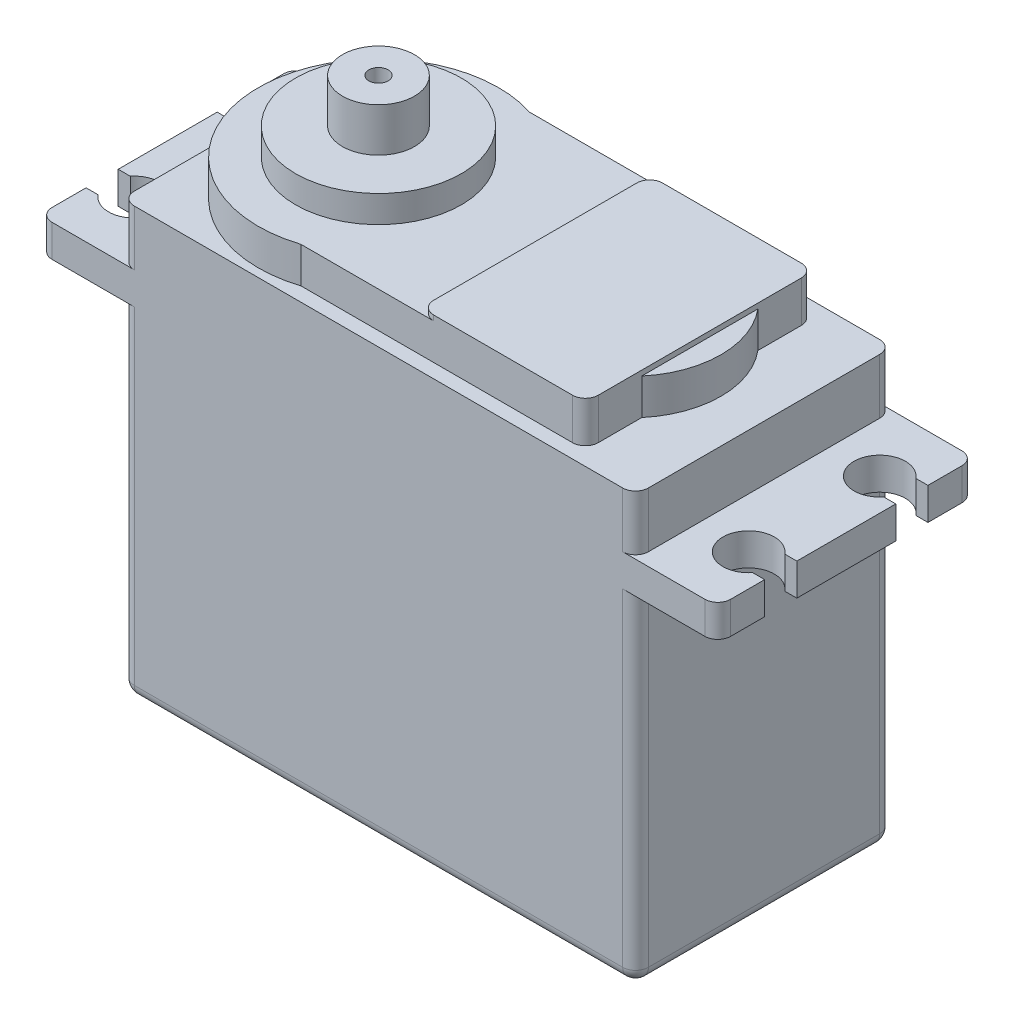
from build123d import *

# Parameters (mm, degrees)
EXTRUDE_1_DEPTH             = 33.3
EXTRUDE_START               = -26.5
EXTRUDE_2_DEPTH             = 2.5
EXTRUDE_START_2             = -33.3
EXTRUDE_3_DEPTH             = 36.1
EXTRUDE_4_DEPTH             = 0.4
SKETCH_6_R                  = 6.45
EXTRUDE_5_DEPTH             = 2.1
SKETCH_7_R                  = 2.8
SKETCH_7_R_2                = 0.75
EXTRUDE_6_DEPTH             = 3.4
FILLET_1_R                  = 1
CUT_EXTRUDE_1_REACH         = 60.258
SKETCH_8_R                  = 2
EXTRUDE_7_DEPTH             = 4.4
EXTRUDE_7_DIRECTION_2_REACH = 67.449


with BuildPart() as part:
    # Эскиз1 → Вытянуть1 (new body)
    with BuildSketch(Plane(origin=(0, 0, 0), x_dir=(1, 0, 0), z_dir=(0, 1, 0))):
        with BuildLine():
            Line((1, 0), (39, 0))
            ThreePointArc((39, 0), (39.707106781, 0.292893219), (40, 1))
            Line((40, 1), (40, 19))
            ThreePointArc((40, 19), (39.707106781, 19.707106781), (39, 20))
            Line((39, 20), (1, 20))
            ThreePointArc((1, 20), (0.292893219, 19.707106781), (0, 19))
            Line((0, 19), (0, 1))
            ThreePointArc((0, 1), (0.292893219, 0.292893219), (1, 0))
        make_face()
    extrude(amount=EXTRUDE_1_DEPTH)

    # Эскиз2 → Вытянуть2 (add)
    with BuildSketch(Plane.XZ.offset(EXTRUDE_START)):
        with BuildLine():
            Line((-5.4, 0), (45.4, 0))
            ThreePointArc((45.4, 0), (46.107106781, -0.292893219), (46.4, -1))
            Line((46.4, -1), (46.4, -19))
            ThreePointArc((46.4, -19), (46.107106781, -19.707106781), (45.4, -20))
            Line((45.4, -20), (-5.4, -20))
            ThreePointArc((-5.4, -20), (-6.107106781, -19.707106781), (-6.4, -19))
            Line((-6.4, -19), (-6.4, -1))
            ThreePointArc((-6.4, -1), (-6.107106781, -0.292893219), (-5.4, 0))
        make_face()
    extrude(amount=-EXTRUDE_2_DEPTH)

    # Эскиз3 → Вытянуть3 (add)
    with BuildSketch(Plane(origin=(0, 33.3, 0), x_dir=(1, 0, 0), z_dir=(0, 1, 0)).offset(EXTRUDE_START_2)):
        with BuildLine():
            Line((12.865745976, 18.9), (34, 18.9))
            ThreePointArc((34, 18.9), (34.707106781, 18.607106781), (35, 17.9))
            Line((35, 17.9), (35, 14.514144437))
            ThreePointArc((35, 14.514144437), (36.65, 10), (35, 5.485855563))
            Line((35, 5.485855563), (35, 2.1))
            ThreePointArc((35, 2.1), (34.707106781, 1.392893219), (34, 1.1))
            Line((34, 1.1), (12.865745976, 1.1))
            ThreePointArc((12.865745976, 1.1), (0.65, 10), (12.865745976, 18.9))
        make_face()
    extrude(amount=EXTRUDE_3_DEPTH)

    # Эскиз5 → Вытянуть4 (add)
    with BuildSketch(Plane(origin=(0, 36.1, 0), x_dir=(1, 0, 0), z_dir=(0, 1, 0))):
        with BuildLine():
            Line((23.2, 18.9), (34, 18.9))
            ThreePointArc((34, 18.9), (34.707106781, 18.607106781), (35, 17.9))
            Line((35, 17.9), (35, 2.1))
            ThreePointArc((35, 2.1), (34.707106781, 1.392893219), (34, 1.1))
            Line((34, 1.1), (23.2, 1.1))
            ThreePointArc((23.2, 1.1), (22.492893219, 1.392893219), (22.2, 2.1))
            Line((22.2, 2.1), (22.2, 17.9))
            ThreePointArc((22.2, 17.9), (22.492893219, 18.607106781), (23.2, 18.9))
        make_face()
    extrude(amount=EXTRUDE_4_DEPTH)

    # Эскиз6 → Вытянуть5 (add)
    with BuildSketch(Plane(origin=(0, 36.1, 0), x_dir=(1, 0, 0), z_dir=(0, 1, 0))):
        with Locations(Location((10, 10, 0), (0, 0, 270))):
            Circle(SKETCH_6_R)
    extrude(amount=EXTRUDE_5_DEPTH)

    # Эскиз7 → Вытянуть6 (add)
    with BuildSketch(Plane(origin=(0, 38.2, 0), x_dir=(1, 0, 0), z_dir=(0, 1, 0))):
        with Locations(Location((10, 10, 0), (0, 0, 270))):
            Circle(SKETCH_7_R)
        with Locations(Location((10, 10, 0), (0, 0, 270))):
            Circle(SKETCH_7_R_2, mode=Mode.SUBTRACT)
    extrude(amount=EXTRUDE_6_DEPTH)

    # Скругление1
    fillet_1_edges = [part.edges().sort_by_distance(p)[0] for p in [
        (20, 0, -20),
        (39.707106781, 0, -19.707106781),
        (40, 0, -10),
        (39.707106781, 0, -0.292893219),
        (20, 0, 0),
        (0.292893219, 0, -0.292893219),
        (0, 0, -10),
        (0.292893219, 0, -19.707106781),
    ]]
    fillet(fillet_1_edges, radius=FILLET_1_R)

    # Эскиз8 → Вырез-Вытянуть1 (cut, up to next)
    with BuildSketch(Plane(origin=(0, 29, 0), x_dir=(1, 0, 0), z_dir=(0, 1, 0)), mode=Mode.PRIVATE) as cut_extrude_1_sk1:
        with Locations((-3.9, 4.9)):
            Circle(SKETCH_8_R)
    cut_extrude_1_tool1 = extrude(cut_extrude_1_sk1.sketch, amount=-CUT_EXTRUDE_1_REACH, mode=Mode.PRIVATE) & part.part
    # Эскиз8 → Вырез-Вытянуть1 (cut, up to next)
    with BuildSketch(Plane(origin=(0, 29, 0), x_dir=(1, 0, 0), z_dir=(0, 1, 0)), mode=Mode.PRIVATE) as cut_extrude_1_sk2:
        with Locations((-3.9, 15.1)):
            Circle(SKETCH_8_R)
    cut_extrude_1_tool2 = extrude(cut_extrude_1_sk2.sketch, amount=-CUT_EXTRUDE_1_REACH, mode=Mode.PRIVATE) & part.part
    # Эскиз8 → Вырез-Вытянуть1 (cut, up to next)
    with BuildSketch(Plane(origin=(0, 29, 0), x_dir=(1, 0, 0), z_dir=(0, 1, 0)), mode=Mode.PRIVATE) as cut_extrude_1_sk3:
        with Locations((43.9, 15.1)):
            Circle(SKETCH_8_R)
    cut_extrude_1_tool3 = extrude(cut_extrude_1_sk3.sketch, amount=-CUT_EXTRUDE_1_REACH, mode=Mode.PRIVATE) & part.part
    # Эскиз8 → Вырез-Вытянуть1 (cut, up to next)
    with BuildSketch(Plane(origin=(0, 29, 0), x_dir=(1, 0, 0), z_dir=(0, 1, 0)), mode=Mode.PRIVATE) as cut_extrude_1_sk4:
        with Locations((43.9, 4.9)):
            Circle(SKETCH_8_R)
    cut_extrude_1_tool4 = extrude(cut_extrude_1_sk4.sketch, amount=-CUT_EXTRUDE_1_REACH, mode=Mode.PRIVATE) & part.part
    # Эскиз8 → Вырез-Вытянуть1 (cut, up to next)
    with BuildSketch(Plane(origin=(0, 29, 0), x_dir=(1, 0, 0), z_dir=(0, 1, 0)), mode=Mode.PRIVATE) as cut_extrude_1_sk5:
        with BuildLine():
            ThreePointArc((-5.4612495, 13.85), (-5.9, 15.1), (-5.4612495, 16.35))
            Line((-5.4612495, 16.35), (-6.4, 16.35))
            Line((-6.4, 16.35), (-6.4, 13.85))
            Line((-6.4, 13.85), (-5.4612495, 13.85))
        make_face()
    cut_extrude_1_tool5 = extrude(cut_extrude_1_sk5.sketch, amount=-CUT_EXTRUDE_1_REACH, mode=Mode.PRIVATE) & part.part
    # Эскиз8 → Вырез-Вытянуть1 (cut, up to next)
    with BuildSketch(Plane(origin=(0, 29, 0), x_dir=(1, 0, 0), z_dir=(0, 1, 0)), mode=Mode.PRIVATE) as cut_extrude_1_sk6:
        with BuildLine():
            ThreePointArc((-1.9, 15.1), (-3.237617557, 16.987127314), (-5.4612495, 16.35))
            Line((-5.4612495, 16.35), (-5.4612495, 13.85))
            ThreePointArc((-5.4612495, 13.85), (-3.237617557, 13.212872686), (-1.9, 15.1))
        make_face()
    cut_extrude_1_tool6 = extrude(cut_extrude_1_sk6.sketch, amount=-CUT_EXTRUDE_1_REACH, mode=Mode.PRIVATE) & part.part
    # Эскиз8 → Вырез-Вытянуть1 (cut, up to next)
    with BuildSketch(Plane(origin=(0, 29, 0), x_dir=(1, 0, 0), z_dir=(0, 1, 0)), mode=Mode.PRIVATE) as cut_extrude_1_sk7:
        with BuildLine():
            Line((-5.4612495, 13.85), (-5.4612495, 16.35))
            ThreePointArc((-5.4612495, 16.35), (-5.9, 15.1), (-5.4612495, 13.85))
        make_face()
    cut_extrude_1_tool7 = extrude(cut_extrude_1_sk7.sketch, amount=-CUT_EXTRUDE_1_REACH, mode=Mode.PRIVATE) & part.part
    # Эскиз8 → Вырез-Вытянуть1 (cut, up to next)
    with BuildSketch(Plane(origin=(0, 29, 0), x_dir=(1, 0, 0), z_dir=(0, 1, 0)), mode=Mode.PRIVATE) as cut_extrude_1_sk8:
        with BuildLine():
            ThreePointArc((-1.9, 4.9), (-3.237617557, 6.787127314), (-5.4612495, 6.15))
            Line((-5.4612495, 6.15), (-5.4612495, 3.65))
            ThreePointArc((-5.4612495, 3.65), (-3.237617557, 3.012872686), (-1.9, 4.9))
        make_face()
    cut_extrude_1_tool8 = extrude(cut_extrude_1_sk8.sketch, amount=-CUT_EXTRUDE_1_REACH, mode=Mode.PRIVATE) & part.part
    # Эскиз8 → Вырез-Вытянуть1 (cut, up to next)
    with BuildSketch(Plane(origin=(0, 29, 0), x_dir=(1, 0, 0), z_dir=(0, 1, 0)), mode=Mode.PRIVATE) as cut_extrude_1_sk9:
        with BuildLine():
            Line((-5.4612495, 3.65), (-5.4612495, 6.15))
            ThreePointArc((-5.4612495, 6.15), (-5.9, 4.9), (-5.4612495, 3.65))
        make_face()
    cut_extrude_1_tool9 = extrude(cut_extrude_1_sk9.sketch, amount=-CUT_EXTRUDE_1_REACH, mode=Mode.PRIVATE) & part.part
    # Эскиз8 → Вырез-Вытянуть1 (cut, up to next)
    with BuildSketch(Plane(origin=(0, 29, 0), x_dir=(1, 0, 0), z_dir=(0, 1, 0)), mode=Mode.PRIVATE) as cut_extrude_1_sk10:
        with BuildLine():
            Line((-5.4612495, 6.15), (-6.4, 6.15))
            Line((-6.4, 6.15), (-6.4, 3.65))
            Line((-6.4, 3.65), (-5.4612495, 3.65))
            ThreePointArc((-5.4612495, 3.65), (-5.9, 4.9), (-5.4612495, 6.15))
        make_face()
    cut_extrude_1_tool10 = extrude(cut_extrude_1_sk10.sketch, amount=-CUT_EXTRUDE_1_REACH, mode=Mode.PRIVATE) & part.part
    # Эскиз8 → Вырез-Вытянуть1 (cut, up to next)
    with BuildSketch(Plane(origin=(0, 29, 0), x_dir=(1, 0, 0), z_dir=(0, 1, 0)), mode=Mode.PRIVATE) as cut_extrude_1_sk11:
        with BuildLine():
            ThreePointArc((45.9, 15.1), (45.787127314, 15.762382443), (45.4612495, 16.35))
            Line((45.4612495, 16.35), (45.4612495, 13.85))
            ThreePointArc((45.4612495, 13.85), (45.787127314, 14.437617557), (45.9, 15.1))
        make_face()
    cut_extrude_1_tool11 = extrude(cut_extrude_1_sk11.sketch, amount=-CUT_EXTRUDE_1_REACH, mode=Mode.PRIVATE) & part.part
    # Эскиз8 → Вырез-Вытянуть1 (cut, up to next)
    with BuildSketch(Plane(origin=(0, 29, 0), x_dir=(1, 0, 0), z_dir=(0, 1, 0)), mode=Mode.PRIVATE) as cut_extrude_1_sk12:
        with BuildLine():
            Line((45.4612495, 13.85), (45.4612495, 16.35))
            ThreePointArc((45.4612495, 16.35), (41.9, 15.1), (45.4612495, 13.85))
        make_face()
    cut_extrude_1_tool12 = extrude(cut_extrude_1_sk12.sketch, amount=-CUT_EXTRUDE_1_REACH, mode=Mode.PRIVATE) & part.part
    # Эскиз8 → Вырез-Вытянуть1 (cut, up to next)
    with BuildSketch(Plane(origin=(0, 29, 0), x_dir=(1, 0, 0), z_dir=(0, 1, 0)), mode=Mode.PRIVATE) as cut_extrude_1_sk13:
        with BuildLine():
            Line((46.4, 16.35), (45.4612495, 16.35))
            ThreePointArc((45.4612495, 16.35), (45.787127314, 15.762382443), (45.9, 15.1))
            ThreePointArc((45.9, 15.1), (45.787127314, 14.437617557), (45.4612495, 13.85))
            Line((45.4612495, 13.85), (46.4, 13.85))
            Line((46.4, 13.85), (46.4, 16.35))
        make_face()
    cut_extrude_1_tool13 = extrude(cut_extrude_1_sk13.sketch, amount=-CUT_EXTRUDE_1_REACH, mode=Mode.PRIVATE) & part.part
    # Эскиз8 → Вырез-Вытянуть1 (cut, up to next)
    with BuildSketch(Plane(origin=(0, 29, 0), x_dir=(1, 0, 0), z_dir=(0, 1, 0)), mode=Mode.PRIVATE) as cut_extrude_1_sk14:
        with BuildLine():
            ThreePointArc((45.9, 4.9), (45.787127314, 5.562382443), (45.4612495, 6.15))
            Line((45.4612495, 6.15), (45.4612495, 3.65))
            ThreePointArc((45.4612495, 3.65), (45.787127314, 4.237617557), (45.9, 4.9))
        make_face()
    cut_extrude_1_tool14 = extrude(cut_extrude_1_sk14.sketch, amount=-CUT_EXTRUDE_1_REACH, mode=Mode.PRIVATE) & part.part
    # Эскиз8 → Вырез-Вытянуть1 (cut, up to next)
    with BuildSketch(Plane(origin=(0, 29, 0), x_dir=(1, 0, 0), z_dir=(0, 1, 0)), mode=Mode.PRIVATE) as cut_extrude_1_sk15:
        with BuildLine():
            Line((45.4612495, 3.65), (45.4612495, 6.15))
            ThreePointArc((45.4612495, 6.15), (41.9, 4.9), (45.4612495, 3.65))
        make_face()
    cut_extrude_1_tool15 = extrude(cut_extrude_1_sk15.sketch, amount=-CUT_EXTRUDE_1_REACH, mode=Mode.PRIVATE) & part.part
    # Эскиз8 → Вырез-Вытянуть1 (cut, up to next)
    with BuildSketch(Plane(origin=(0, 29, 0), x_dir=(1, 0, 0), z_dir=(0, 1, 0)), mode=Mode.PRIVATE) as cut_extrude_1_sk16:
        with BuildLine():
            Line((46.4, 6.15), (45.4612495, 6.15))
            ThreePointArc((45.4612495, 6.15), (45.787127314, 5.562382443), (45.9, 4.9))
            ThreePointArc((45.9, 4.9), (45.787127314, 4.237617557), (45.4612495, 3.65))
            Line((45.4612495, 3.65), (46.4, 3.65))
            Line((46.4, 3.65), (46.4, 6.15))
        make_face()
    cut_extrude_1_tool16 = extrude(cut_extrude_1_sk16.sketch, amount=-CUT_EXTRUDE_1_REACH, mode=Mode.PRIVATE) & part.part
    add(cut_extrude_1_tool1.solids().sort_by_distance((-3.9, 29, -4.9))[0], mode=Mode.SUBTRACT)
    add(cut_extrude_1_tool2.solids().sort_by_distance((-3.9, 29, -15.1))[0], mode=Mode.SUBTRACT)
    add(cut_extrude_1_tool3.solids().sort_by_distance((43.9, 29, -15.1))[0], mode=Mode.SUBTRACT)
    add(cut_extrude_1_tool4.solids().sort_by_distance((43.9, 29, -4.9))[0], mode=Mode.SUBTRACT)
    add(cut_extrude_1_tool5.solids().sort_by_distance((-6.067542, 29, -15.1))[0], mode=Mode.SUBTRACT)
    add(cut_extrude_1_tool6.solids().sort_by_distance((-3.789816, 29, -15.1))[0], mode=Mode.SUBTRACT)
    add(cut_extrude_1_tool7.solids().sort_by_distance((-5.638512, 29, -15.1))[0], mode=Mode.SUBTRACT)
    add(cut_extrude_1_tool8.solids().sort_by_distance((-3.789816, 29, -4.9))[0], mode=Mode.SUBTRACT)
    add(cut_extrude_1_tool9.solids().sort_by_distance((-5.638512, 29, -4.9))[0], mode=Mode.SUBTRACT)
    add(cut_extrude_1_tool10.solids().sort_by_distance((-6.067542, 29, -4.9))[0], mode=Mode.SUBTRACT)
    add(cut_extrude_1_tool11.solids().sort_by_distance((45.638512, 29, -15.1))[0], mode=Mode.SUBTRACT)
    add(cut_extrude_1_tool12.solids().sort_by_distance((43.789816, 29, -15.1))[0], mode=Mode.SUBTRACT)
    add(cut_extrude_1_tool13.solids().sort_by_distance((46.067542, 29, -15.1))[0], mode=Mode.SUBTRACT)
    add(cut_extrude_1_tool14.solids().sort_by_distance((45.638512, 29, -4.9))[0], mode=Mode.SUBTRACT)
    add(cut_extrude_1_tool15.solids().sort_by_distance((43.789816, 29, -4.9))[0], mode=Mode.SUBTRACT)
    add(cut_extrude_1_tool16.solids().sort_by_distance((46.067542, 29, -4.9))[0], mode=Mode.SUBTRACT)

    # Эскиз10 → Вытянуть7 (add)
    with BuildSketch(Plane.ZY):
        with BuildLine():
            Line((-12, 0.5), (-8, 0.5))
            ThreePointArc((-8, 0.5), (-7.292893219, 0.792893219), (-7, 1.5))
            Line((-7, 1.5), (-7, 3.5))
            ThreePointArc((-7, 3.5), (-7.292893219, 4.207106781), (-8, 4.5))
            Line((-8, 4.5), (-12, 4.5))
            ThreePointArc((-12, 4.5), (-12.707106781, 4.207106781), (-13, 3.5))
            Line((-13, 3.5), (-13, 1.5))
            ThreePointArc((-13, 1.5), (-12.707106781, 0.792893219), (-12, 0.5))
        make_face()
    extrude(amount=EXTRUDE_7_DEPTH)

    # Эскиз10 → Вытянуть7 direction 2 (add, up to next)
    with BuildSketch(Plane.ZY, mode=Mode.PRIVATE) as extrude_7_direction_2_sk1:
        with BuildLine():
            Line((-12, 0.5), (-8, 0.5))
            ThreePointArc((-8, 0.5), (-7.292893219, 0.792893219), (-7, 1.5))
            Line((-7, 1.5), (-7, 3.5))
            ThreePointArc((-7, 3.5), (-7.292893219, 4.207106781), (-8, 4.5))
            Line((-8, 4.5), (-12, 4.5))
            ThreePointArc((-12, 4.5), (-12.707106781, 4.207106781), (-13, 3.5))
            Line((-13, 3.5), (-13, 1.5))
            ThreePointArc((-13, 1.5), (-12.707106781, 0.792893219), (-12, 0.5))
        make_face()
    extrude_7_direction_2_tool1 = extrude(extrude_7_direction_2_sk1.sketch, amount=-EXTRUDE_7_DIRECTION_2_REACH, mode=Mode.PRIVATE) - part.part
    add(extrude_7_direction_2_tool1.solids().sort_by_distance((0, 2.5, -10))[0])


solid = part.part
